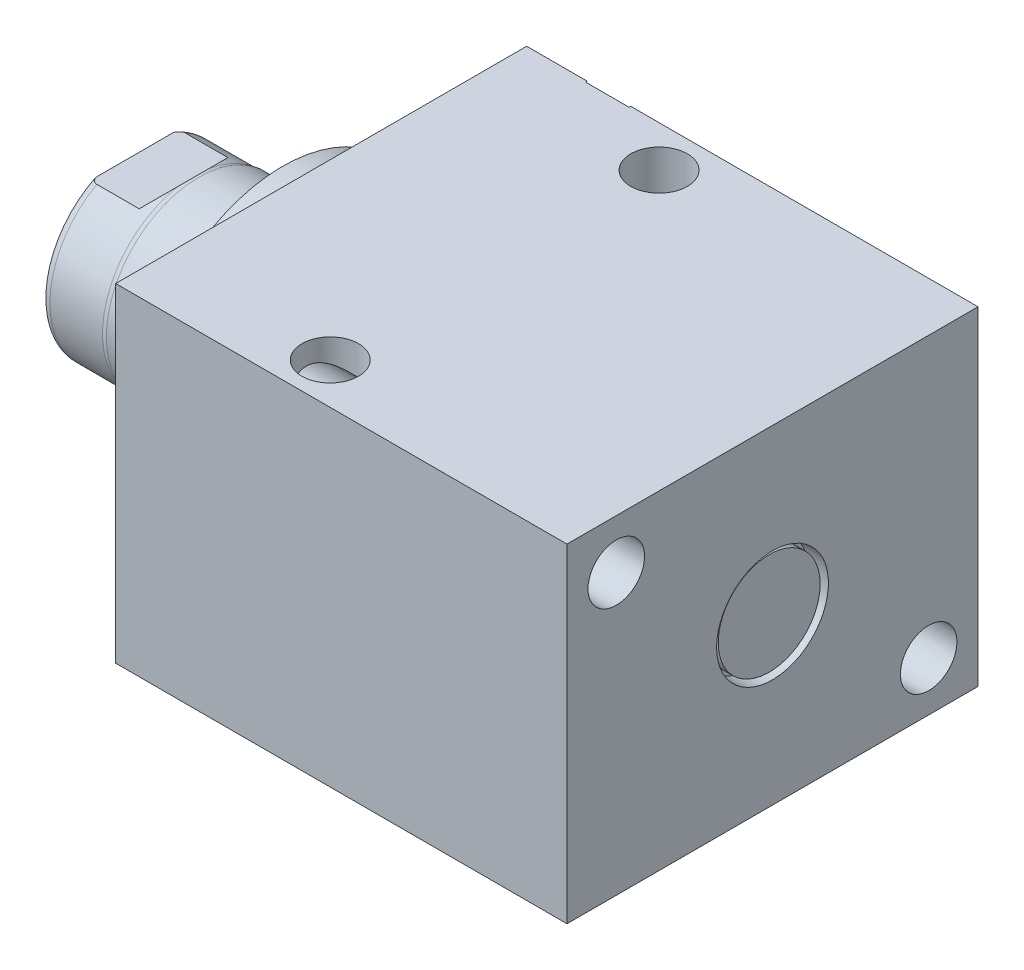
from build123d import *

# Parameters (mm, degrees)
SKETCH1_W            = 63.5
SKETCH1_H            = 50.8
EXTRUDE1_DEPTH       = 69.723
LPATTERN1_COUNT      = 2
LPATTERN1_PITCH      = 41.148
LPATTERN1_COUNT_DIR2 = 2
LPATTERN1_PITCH_DIR2 = 17.4498
SKETCH5_R            = 22.225
EXTRUDE2_DEPTH       = 5.969
SKETCH6_W            = 14.2748
SKETCH6_H            = 22.86
CUT_EXTRUDE4_DEPTH   = 30.48
HOLE1_D              = 8.738
HOLE1_DEPTH          = 69.723
HOLE2_D              = 8.738
HOLE2_DEPTH          = 50.8
EXTRUDE3_DEPTH       = 6.78
SKETCH21_R           = 7.874
EXTRUDE4_DEPTH       = 2.54


with BuildPart() as part:
    # Sketch1 → Extrude1 (new body)
    with BuildSketch(Plane(origin=(0, 0, 0), x_dir=(0, 0, -1), z_dir=(1, 0, 0))):
        Rectangle(SKETCH1_W, SKETCH1_H)
    extrude(amount=EXTRUDE1_DEPTH)

    # S2D0002 → Cut-Revolve1 (revolve, cut)
    with BuildSketch(Plane(origin=(0, 17.4498, 0), x_dir=(-1, 0, 0), z_dir=(0, 1, 0)), mode=Mode.PRIVATE) as cut_revolve1_sk:
        Polygon((-17.7165, -31.496), (-21.336, -31.496), (-21.336, -31.75), (-12.7, -31.75), (-12.7, -18.034), (-17.1196, -18.034), (-17.1196, -30.8737), (-17.7165, -31.4706), align=None)
    cut_revolve1 = revolve(cut_revolve1_sk.sketch.rotate(Axis((12.7, 17.4498, -19.13842003), (0, 0, 1)), 180), axis=Axis((12.7, 17.4498, -19.13842003), (0, 0, 1)), mode=Mode.SUBTRACT)  # turned: the seam where the file's is

    # LPattern1: Cut-Revolve1 2 × 2, 2 skipped
    with Locations(*[(i * LPATTERN1_PITCH, -j * LPATTERN1_PITCH_DIR2, 0) for i in range(LPATTERN1_COUNT) for j in range(LPATTERN1_COUNT_DIR2) if (i, j) not in ((0, 0), (0, 1), (1, 0))]):
        add(cut_revolve1, mode=Mode.SUBTRACT)

    # Sketch5 → Extrude2 (add)
    with BuildSketch(Plane.ZY):
        Circle(SKETCH5_R)
    extrude(amount=EXTRUDE2_DEPTH)

    # Sketch6 → Revolve1 (revolve)
    with BuildSketch(Plane(origin=(0, 0, 0), x_dir=(0, 0, 1), z_dir=(0, -1, 0)), mode=Mode.PRIVATE) as revolve1_sk:
        with Locations((-7.1374, 17.399)):
            Rectangle(SKETCH6_W, SKETCH6_H)
    revolve(revolve1_sk.sketch.rotate(Axis((5.754582971, 0, 0), (-1, 0, 0)), 180), axis=Axis((5.754582971, 0, 0), (-1, 0, 0)))  # turned: the seam where the file's is

    # S2D0001 → Cut-Revolve4 (revolve, cut)
    with BuildSketch(Plane(origin=(-18.511260017, 3.2639, 0), x_dir=(0, 1, 0), z_dir=(0, 0, 1)), mode=Mode.PRIVATE) as cut_revolve4_sk:
        Polygon((1.8669, 8.206023638), (1.8669, -6.522460017), (-3.2639, -6.522460017), (-3.2639, 10.317739983), (3.0861, 10.317739983), align=None)
    revolve(cut_revolve4_sk.sketch.rotate(Axis((0, 0, 0), (-1, 0, 0)), 90), axis=Axis((0, 0, 0), (-1, 0, 0)), mode=Mode.SUBTRACT)  # turned: the seam where the file's is

    # Sketch8 → Cut-Revolve5 (revolve, cut)
    with BuildSketch(Plane(origin=(0, 0, 0), x_dir=(0, 0, -1), z_dir=(0, 1, 0)), mode=Mode.PRIVATE) as cut_revolve5_sk:
        with BuildLine():
            Line((-14.2748, 18.923), (-14.097, 19.685))
            Line((-14.097, 19.685), (-14.097, 27.813))
            ThreePointArc((-14.097, 27.813), (-13.996678675, 28.356796865), (-13.708922533, 28.829))
            Line((-13.708922533, 28.829), (-14.2748, 28.829))
            Line((-14.2748, 28.829), (-14.2748, 18.923))
        make_face()
    revolve(cut_revolve5_sk.sketch.rotate(Axis((-12.65936, 0, 0), (-1, 0, 0)), 180), axis=Axis((-12.65936, 0, 0), (-1, 0, 0)), mode=Mode.SUBTRACT)  # turned: the seam where the file's is

    # Sketch12 → Cut-Extrude4 (cut, symmetric)
    with BuildSketch(Plane(origin=(0, 0, 0), x_dir=(0, -1, 0), z_dir=(0, 0, -1))):
        Polygon((12.319, 28.829), (12.319, 21.2598), (14.2748, 19.304), (14.2748, 28.829), align=None)
        Polygon((-12.319, 28.829), (-12.319, 21.2598), (-14.2748, 19.304), (-14.2748, 28.829), align=None)
    extrude(amount=CUT_EXTRUDE4_DEPTH, both=True, mode=Mode.SUBTRACT)

    # Hole1
    with Locations(Plane.ZY):
        with Locations((-24.13, -17.78), (24.13, 17.78)):
            Hole(HOLE1_D / 2, depth=HOLE1_DEPTH)

    # Hole2
    with Locations(Plane(origin=(0, 25.4, 0), x_dir=(-1, 0, 0), z_dir=(0, 1, 0))):
        with Locations((-26.797, -25.4), (-26.797, 25.4)):
            Hole(HOLE2_D / 2, depth=HOLE2_DEPTH)

    # Sketch18 → Extrude3 (add)
    with BuildSketch(Plane(origin=(0, 0, -31.496), x_dir=(-1, 0, 0), z_dir=(0, 0, -1))):
        Polygon((-46.863, 4.03279163), (-53.848, 8.065583261), (-60.833, 4.03279163), (-60.833, -4.03279163), (-53.848, -8.065583261), (-46.863, -4.03279163), align=None)
    extrude(amount=EXTRUDE3_DEPTH)

    # Sketch19 → Cut-Revolve6 (revolve, cut)
    with BuildSketch(Plane(origin=(0, 0, 0), x_dir=(-1, 0, 0), z_dir=(0, 1, 0)), mode=Mode.PRIVATE) as cut_revolve6_sk:
        with BuildLine():
            Line((-60.071, -38.276), (-60.071, -40.689))
            Line((-60.071, -40.689), (-63.246, -40.689))
            Line((-63.246, -40.689), (-63.246, -37.514))
            Line((-63.246, -37.514), (-60.833, -37.514))
            ThreePointArc((-60.833, -37.514), (-60.609815367, -38.052815367), (-60.071, -38.276))
        make_face()
    revolve(cut_revolve6_sk.sketch.rotate(Axis((53.848, 0, -18.51025594), (0, 0, -1)), 180), axis=Axis((53.848, 0, -18.51025594), (0, 0, -1)), mode=Mode.SUBTRACT)  # turned: the seam where the file's is

    # Sketch20 → Cut-Revolve7 (revolve, cut)
    with BuildSketch(Plane(origin=(0, 0, 0), x_dir=(1, 0, 0), z_dir=(0, 1, 0)), mode=Mode.PRIVATE) as cut_revolve7_sk:
        Polygon((69.723, 8.636), (66.675, 8.636), (66.675, 5.0165), (66.6496, 5.0165), (66.0527, 4.4196), (56.1086, 4.4196), (56.1086, 0), (69.723, 0), align=None)
    revolve(cut_revolve7_sk.sketch.rotate(Axis((0, 0, 0), (1, 0, 0)), 180), axis=Axis((0, 0, 0), (1, 0, 0)), mode=Mode.SUBTRACT)  # turned: the seam where the file's is

    # Sketch21 → Extrude4 (add)
    with BuildSketch(Plane(origin=(66.675, 0, 0), x_dir=(0, 0, -1), z_dir=(1, 0, 0))):
        Circle(SKETCH21_R)
    extrude(amount=EXTRUDE4_DEPTH)


solid = part.part
